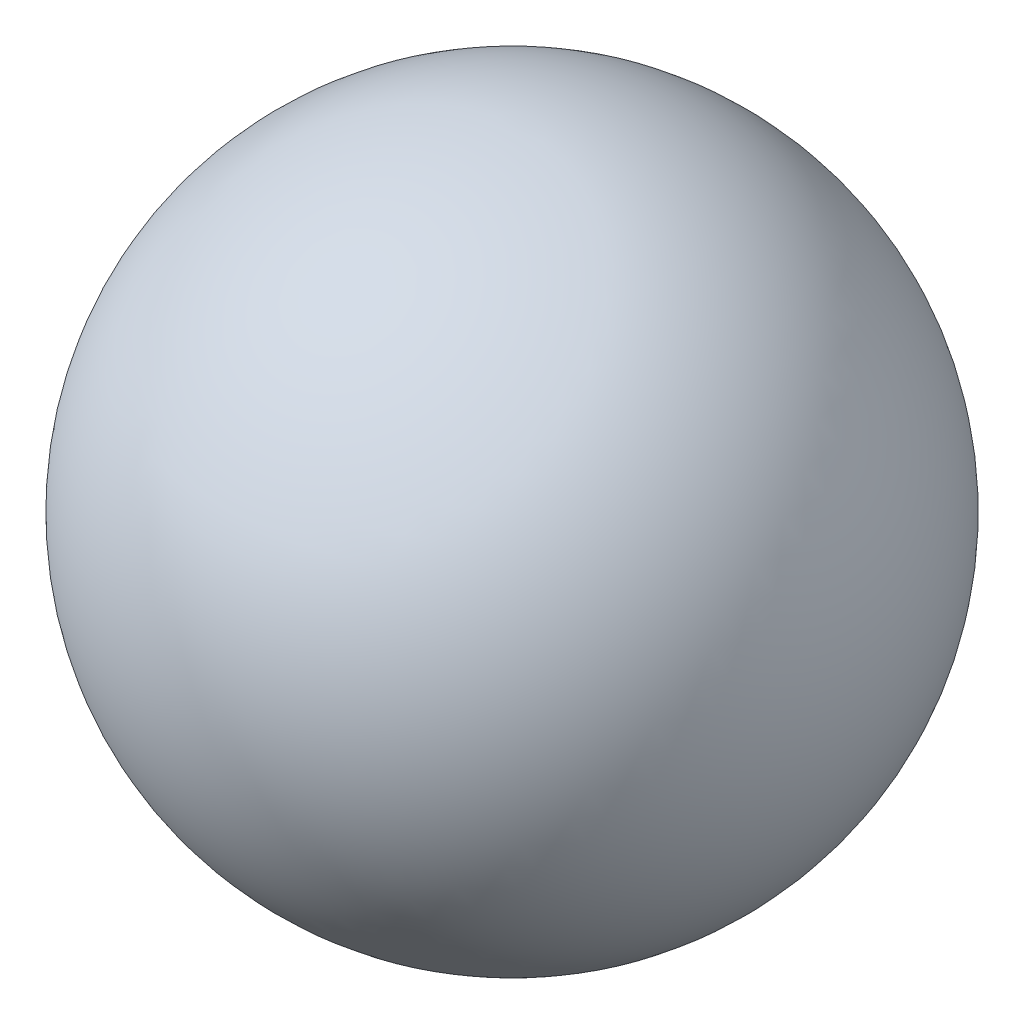
from build123d import *


with BuildPart() as part:
    # 草图1 → 旋转1 (revolve)
    with BuildSketch(Plane.XY):
        with BuildLine():
            Line((0, 34), (0, -34))
            ThreePointArc((0, -34), (-34, 0), (0, 34))
        make_face()
    revolve(axis=Axis((0, 34, 0), (0, -1, 0)))


solid = part.part
